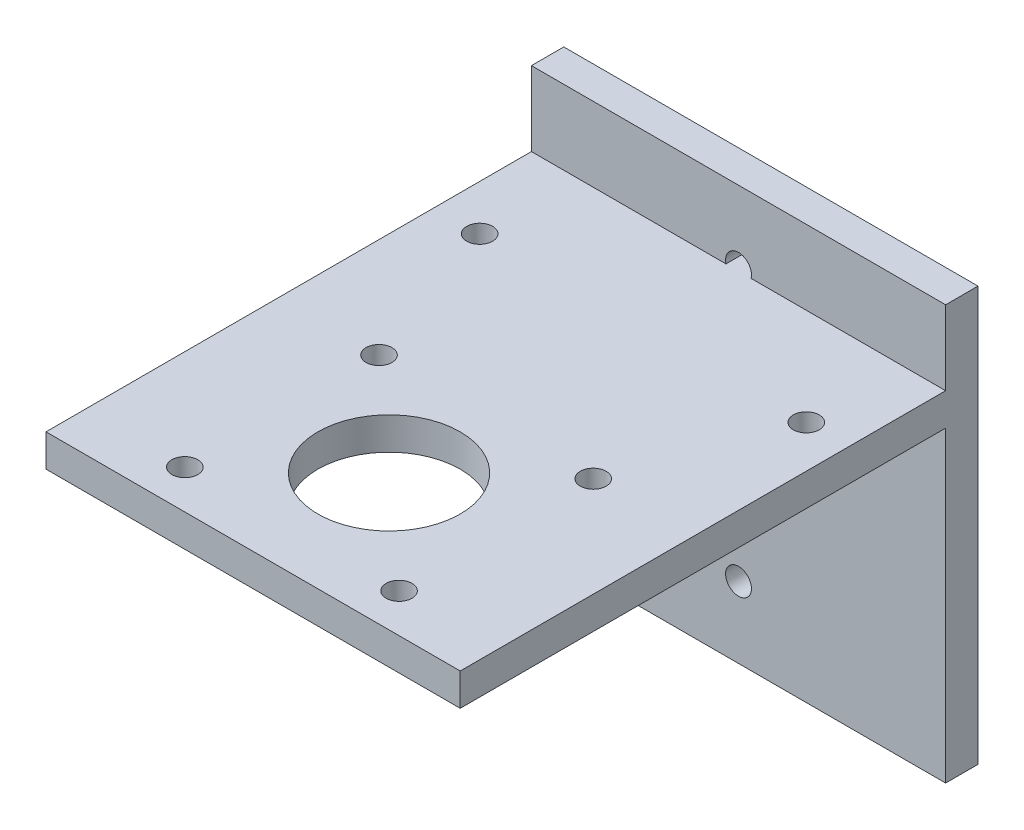
from build123d import *

# Parameters (mm, degrees)
ESBO_O1_W                = 64
ESBO_O1_H                = 64
ESBO_O1_R                = 2
RESSALTO_EXTRUS_O1_DEPTH = 5
ESBO_O2_W                = 64
ESBO_O2_H                = 5
RESSALTO_EXTRUS_O3_DEPTH = 80
ESBO_O3_R                = 11
ESBO_O3_R_2              = 2
CORTE_EXTRUS_O1_DEPTH    = 114


with BuildPart() as part:
    # Esboço1 → Ressalto-extrusão1 (new body)
    with BuildSketch(Plane.XY):
        with Locations((32, 32)):
            Rectangle(ESBO_O1_W, ESBO_O1_H)
        with Locations((32, 42.5)):
            Circle(ESBO_O1_R, mode=Mode.SUBTRACT)
        with Locations((32, 32)):
            Circle(ESBO_O1_R, mode=Mode.SUBTRACT)
        with Locations((32, 21.5)):
            Circle(ESBO_O1_R, mode=Mode.SUBTRACT)
        with Locations((32, 53)):
            Circle(ESBO_O1_R, mode=Mode.SUBTRACT)
        with Locations((32, 11)):
            Circle(ESBO_O1_R, mode=Mode.SUBTRACT)
    extrude(amount=RESSALTO_EXTRUS_O1_DEPTH)

    # Esboço2 → Ressalto-extrusão3 (add)
    with BuildSketch(Plane.XY):
        with Locations((32, 50)):
            Rectangle(ESBO_O2_W, ESBO_O2_H)
    extrude(amount=RESSALTO_EXTRUS_O3_DEPTH)

    # Esboço3 → Corte-extrusão1 (cut)
    with BuildSketch(Plane(origin=(0, 0, 0), x_dir=(1, 0, 0), z_dir=(0, 1, 0))):
        with Locations((32, -59)):
            Circle(ESBO_O3_R)
        with Locations((15.45, -74)):
            Circle(ESBO_O3_R_2)
        with Locations((48.55, -74)):
            Circle(ESBO_O3_R_2)
        with Locations((15.45, -44)):
            Circle(ESBO_O3_R_2)
        with Locations((48.55, -44)):
            Circle(ESBO_O3_R_2)
        with Locations((7.003644385, -20)):
            Circle(ESBO_O3_R_2)
        with Locations((57.465770744, -20)):
            Circle(ESBO_O3_R_2)
    extrude(amount=CORTE_EXTRUS_O1_DEPTH, mode=Mode.SUBTRACT)


solid = part.part
